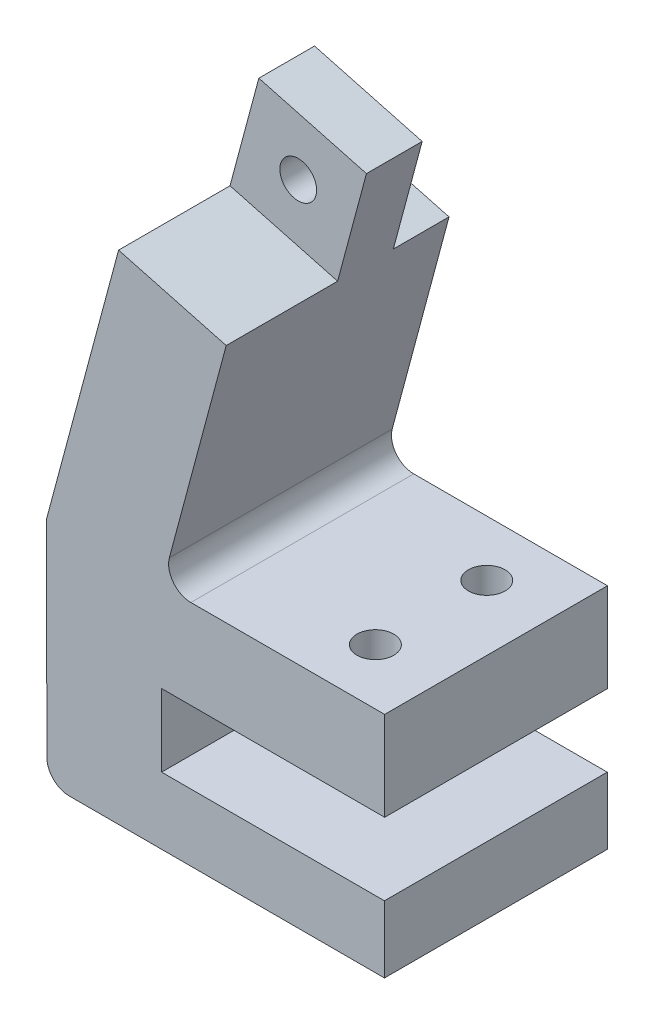
from build123d import *

# Parameters (mm, degrees)
EXTRUDE_1_DEPTH             = 20
FILLET_1_R                  = 2
FILLET_2_R                  = 2
CUT_EXTRUDE_2_DEPTH         = 10
SKETCH_34_R                 = 3.25
CUT_EXTRUDE_3_DEPTH         = 6
HOLE_WIZARD_M4_2_D          = 3.3
HOLE_WIZARD_M4_2_DEPTH      = 4
SKETCH_38_W                 = 5
SKETCH_38_H                 = 10
CUT_EXTRUDE_4_DEPTH         = 11
SKETCH_40_W                 = 1.65
SKETCH_40_H                 = 8
HOLE_WIZARD_M4_3_AT_2_COUNT = 2
HOLE_WIZARD_M4_3_AT_2_PITCH = 10
CUT_EXTRUDE_5_DEPTH         = 4.5


with BuildPart() as part:
    # 草图1 → 凸台-拉伸1 (new body)
    with BuildSketch(Plane.XY):
        Polygon((0.020144186, -0.052366179), (0.016918395, 5.947632954), (-19.983081605, 5.947632954), (-20.000068427, 12.447632954), (0.03759791, 12.447632954), (0.03759791, 20.447632954), (-19.96240209, 20.447632954), (-11.597239053, 51.666846423), (-21.256497316, 54.255036874), (-30.315163894, 20.447632954), (-30.279663837, -0.052366179), align=None)
    extrude(amount=EXTRUDE_1_DEPTH)

    # 圆角1
    fillet_1_edges = [part.edges().sort_by_distance(p)[0] for p in [
        (-19.96240209, 20.447632954, 10),
    ]]
    fillet(fillet_1_edges, radius=FILLET_1_R)

    # 圆角2
    fillet_2_edges = [part.edges().sort_by_distance(p)[0] for p in [
        (-30.279663837, -0.052366179, 10),
    ]]
    fillet(fillet_2_edges, radius=FILLET_2_R)

    # 草图33 → 切除-拉伸2 (cut)
    with BuildSketch(Plane.XY.offset(20)):
        Polygon((-21.256497316, 54.255036874), (-11.597239053, 51.666846423), (-14.185429504, 42.00758816), (-23.844687767, 44.595778611), align=None)
    extrude(amount=-CUT_EXTRUDE_2_DEPTH, mode=Mode.SUBTRACT)

    # 草图34 → 切除-拉伸3 (cut)
    with BuildSketch(Plane(origin=(0, 0, 0), x_dir=(-1, 0, 0), z_dir=(0, 0, -1))):
        with Locations((17.72096341, 48.131312517)):
            Circle(SKETCH_34_R)
    extrude(amount=-CUT_EXTRUDE_3_DEPTH, mode=Mode.SUBTRACT)

    # M4 螺纹孔的螺纹孔钻头2
    with Locations(Plane(origin=(0, 0, 6), x_dir=(-1, 0, 0), z_dir=(0, 0, -1))):
        with Locations((17.72096341, 48.131312517)):
            Hole(HOLE_WIZARD_M4_2_D / 2, depth=HOLE_WIZARD_M4_2_DEPTH)

    # 草图38 → 切除-拉伸4 (cut)
    with BuildSketch(Plane(origin=(-23.737082949, 6.360332207, 0), x_dir=(0, 0, -1), z_dir=(0.965925826, -0.258819045, 0))):
        with Locations((-2.5, 41.904754985)):
            Rectangle(SKETCH_38_W, SKETCH_38_H)
    extrude(amount=-CUT_EXTRUDE_4_DEPTH, mode=Mode.SUBTRACT)

    # 草图40 → M4 螺纹孔的螺纹孔钻头3 (revolve, cut)
    with BuildSketch(Plane(origin=(-5.798619526, 12.447632954, 5), x_dir=(0, 0, -1), z_dir=(1, 0, 0))):
        with Locations((0.825, 4)):
            Rectangle(SKETCH_40_W, SKETCH_40_H)
    hole_wizard_m4_3 = revolve(axis=Axis((-5.798619526, 6.097632954, 5), (0, 1, 0)), mode=Mode.SUBTRACT)

    # M4 螺纹孔的螺纹孔钻头3 at 2: M4 螺纹孔的螺纹孔钻头3 ×2
    with Locations(*[(0, 0, i * HOLE_WIZARD_M4_3_AT_2_PITCH) for i in range(1, HOLE_WIZARD_M4_3_AT_2_COUNT)]):
        add(hole_wizard_m4_3, mode=Mode.SUBTRACT)

    # 草图41 → 切除-拉伸5 (cut)
    with BuildSketch(Plane.XZ.offset(-12.447632954)):
        with BuildLine():
            Line((-7.265759602, 12.1), (-4.331479451, 12.1))
            ThreePointArc((-4.331479451, 12.1), (-2.548619526, 15), (-4.331479451, 17.9))
            Line((-4.331479451, 17.9), (-7.265759602, 17.9))
            ThreePointArc((-7.265759602, 17.9), (-9.048619526, 15), (-7.265759602, 12.1))
        make_face()
        with BuildLine():
            Line((-7.265759602, 2.1), (-4.331479451, 2.1))
            ThreePointArc((-4.331479451, 2.1), (-2.548619526, 5), (-4.331479451, 7.9))
            Line((-4.331479451, 7.9), (-7.265759602, 7.9))
            ThreePointArc((-7.265759602, 7.9), (-9.048619526, 5), (-7.265759602, 2.1))
        make_face()
    extrude(amount=-CUT_EXTRUDE_5_DEPTH, mode=Mode.SUBTRACT)


solid = part.part
